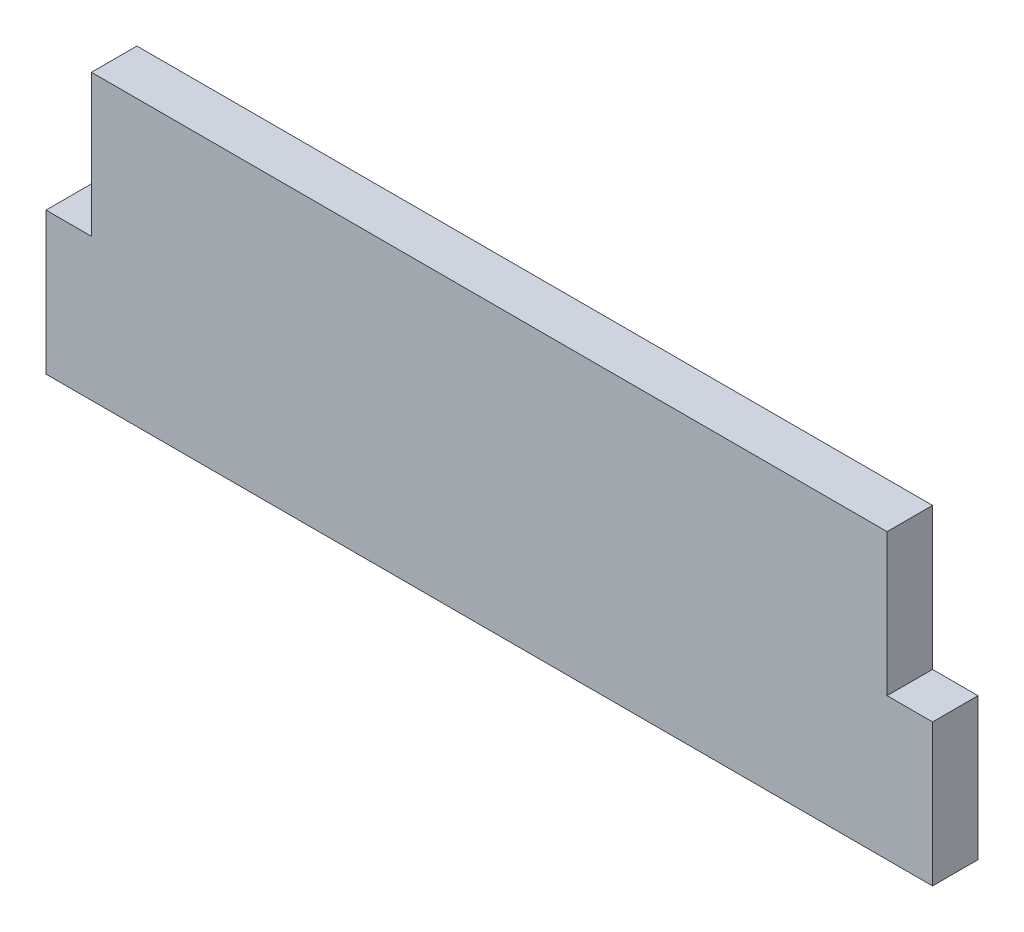
from build123d import *

# Parameters (mm, degrees)
SKETCH2_W           = 5.08
SKETCH2_H           = 15.875
BOSS_EXTRUDE1_DEPTH = 5.08


with BuildPart() as part:
    # Sketch2 → Boss-Extrude1 (new body)
    with BuildSketch(Plane.XY):
        with Locations((-46.99, -7.9375)):
            Rectangle(SKETCH2_W, SKETCH2_H)
        Polygon((-44.45, 15.875), (-44.45, 0), (-44.45, -15.875), (44.45, -15.875), (44.45, 0), (44.45, 15.875), align=None)
        with Locations((46.99, -7.9375)):
            Rectangle(SKETCH2_W, SKETCH2_H)
    extrude(amount=BOSS_EXTRUDE1_DEPTH)


solid = part.part
